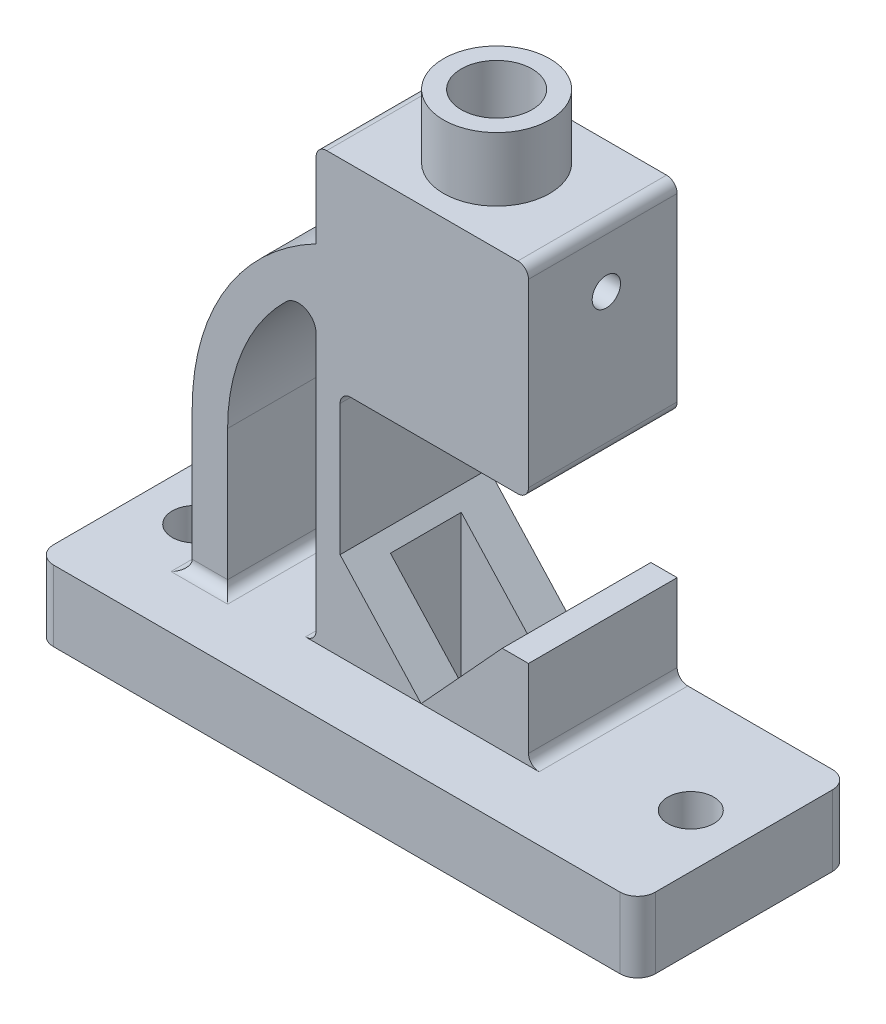
from build123d import *

# Parameters (mm, degrees)
SKETCH1_W           = 170
SKETCH1_H           = 60
BOSS_EXTRUDE1_DEPTH = 20
FILLET1_R           = 5
BOSS_EXTRUDE2_DEPTH = 42
SKETCH5_R           = 15
BOSS_EXTRUDE3_DEPTH = 18
SKETCH6_R           = 10
CUT_EXTRUDE1_DEPTH  = 28
SKETCH7_W           = 40
SKETCH7_H           = 131.983318458
CUT_EXTRUDE2_DEPTH  = 10
FILLET5_R           = 3
SKETCH8_R           = 6.5
CUT_EXTRUDE3_DEPTH  = 20
SKETCH9_R           = 4
CUT_EXTRUDE4_DEPTH  = 60


with BuildPart() as part:
    # Sketch1 → Boss-Extrude1 (new body)
    with BuildSketch(Plane(origin=(0, 0, 0), x_dir=(1, 0, 0), z_dir=(0, 1, 0))):
        Rectangle(SKETCH1_W, SKETCH1_H)
    extrude(amount=BOSS_EXTRUDE1_DEPTH)

    # Fillet1
    fillet1_edges = [part.edges().sort_by_distance(p)[0] for p in [
        (-85, 10, -30),
        (85, 10, -30),
        (85, 10, 30),
        (-85, 10, 30),
    ]]
    fillet(fillet1_edges, radius=FILLET1_R)

    # Sketch4 → Boss-Extrude2 (add)
    with BuildSketch(Plane(origin=(0, 0, 12), x_dir=(-1, 0, 0), z_dir=(0, 0, -1))):
        with BuildLine():
            Line((48.849351026, 20), (58.849351026, 20))
            Line((58.849351026, 20), (58.849351026, 60))
            ThreePointArc((58.849351026, 60), (49.414627953, 93.726843908), (23.849351026, 117.662812973))
            Line((23.849351026, 117.662812973), (23.849351026, 138.983318458))
            ThreePointArc((23.849351026, 138.983318458), (22.970671369, 141.104638801), (20.849351026, 141.983318458))
            Line((20.849351026, 141.983318458), (-33.150648974, 141.983318458))
            ThreePointArc((-33.150648974, 141.983318458), (-35.271969318, 141.104638801), (-36.150648974, 138.983318458))
            Line((-36.150648974, 138.983318458), (-36.150648974, 88))
            ThreePointArc((-36.150648974, 88), (-35.271969318, 85.878679656), (-33.150648974, 85))
            Line((-33.150648974, 85), (14.083425542, 85))
            ThreePointArc((14.083425542, 85), (16.204745885, 84.121320344), (17.083425542, 82))
            Line((17.083425542, 82), (17.083425542, 45))
            Line((17.083425542, 45), (-5.824853809, 20))
            Line((-5.824853809, 20), (23.849351026, 20))
            Line((23.849351026, 20), (23.849351026, 95.707142143))
            ThreePointArc((23.849351026, 95.707142143), (26.912859353, 100.316914371), (32.349351026, 99.277856357))
            ThreePointArc((32.349351026, 99.277856357), (44.556845541, 81.301408404), (48.849351026, 60))
            Line((48.849351026, 60), (48.849351026, 20))
        make_face()
        Polygon((-36.150648974, 20), (-5.824853809, 20), (-28.733133159, 45), (-36.150648974, 45), align=None)
    extrude(amount=BOSS_EXTRUDE2_DEPTH)

    # Sketch5 → Boss-Extrude3 (add)
    with BuildSketch(Plane(origin=(0, 141.983318458, 0), x_dir=(1, 0, 0), z_dir=(0, 1, 0))):
        with Locations((6.150648974, 9)):
            Circle(SKETCH5_R)
    extrude(amount=BOSS_EXTRUDE3_DEPTH)

    # Sketch6 → Cut-Extrude1 (cut)
    with BuildSketch(Plane(origin=(0, 159.983318458, 0), x_dir=(1, 0, 0), z_dir=(0, 1, 0))):
        with Locations((6.150648974, 9)):
            Circle(SKETCH6_R)
    extrude(amount=-CUT_EXTRUDE1_DEPTH, mode=Mode.SUBTRACT)

    # Sketch7 → Cut-Extrude2 (cut, symmetric)
    with BuildSketch(Plane(origin=(0, 0, -9), x_dir=(-1, 0, 0), z_dir=(0, 0, -1))):
        with Locations((-6.150648974, 65.991659229)):
            Rectangle(SKETCH7_W, SKETCH7_H)
    extrude(amount=CUT_EXTRUDE2_DEPTH, both=True, mode=Mode.SUBTRACT)

    # Fillet5
    fillet5_edges = [part.edges().sort_by_distance(p)[0] for p in [
        (36.150648974, 20, -9),
        (-23.849351026, 20, -9),
        (-48.849351026, 20, -9),
        (-53.849351026, 20, 12),
        (-58.849351026, 20, -9),
    ]]
    fillet(fillet5_edges, radius=FILLET5_R)

    # Sketch8 → Cut-Extrude3 (cut)
    with BuildSketch(Plane(origin=(0, 20, 0), x_dir=(1, 0, 0), z_dir=(0, 1, 0))):
        with Locations((-70, 0)):
            Circle(SKETCH8_R)
        with Locations((70, 0)):
            Circle(SKETCH8_R)
    extrude(amount=-CUT_EXTRUDE3_DEPTH, mode=Mode.SUBTRACT)

    # Sketch9 → Cut-Extrude4 (cut)
    with BuildSketch(Plane(origin=(36.150648974, 0, 0), x_dir=(0, 0, -1), z_dir=(1, 0, 0))):
        with Locations((10, 124.983318458)):
            Circle(SKETCH9_R)
    extrude(amount=-CUT_EXTRUDE4_DEPTH, mode=Mode.SUBTRACT)


solid = part.part
